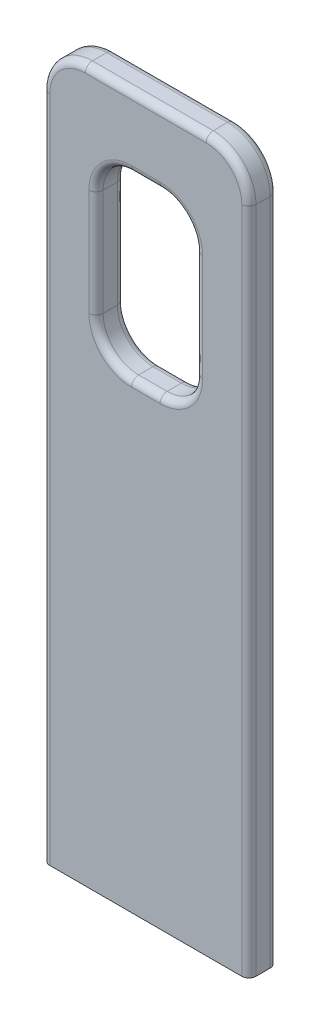
from build123d import *

# Parameters (mm, degrees)
SKETCH1_W      = 2.9
SKETCH1_H      = 10
SKETCH1_W_2    = 1.4
SKETCH1_H_2    = 2.5
EXTRUDE1_DEPTH = 0.2
FILLET1_R      = 0.5
FILLET2_R      = 0.6
FILLET3_R      = 0.1


with BuildPart() as part:
    # Sketch1 → Extrude1 (new body, symmetric)
    with BuildSketch(Plane.XY):
        with Locations((0, 5)):
            Rectangle(SKETCH1_W, SKETCH1_H)
        with Locations((0, 7.75)):
            Rectangle(SKETCH1_W_2, SKETCH1_H_2, mode=Mode.SUBTRACT)
    extrude(amount=EXTRUDE1_DEPTH, both=True)

    # Fillet1
    fillet1_edges = [part.edges().sort_by_distance(p)[0] for p in [
        (-0.7, 9, 0),
        (-0.7, 6.5, 0),
        (0.7, 6.5, 0),
        (0.7, 9, 0),
    ]]
    fillet(fillet1_edges, radius=FILLET1_R)

    # Fillet2
    fillet2_edges = [part.edges().sort_by_distance(p)[0] for p in [
        (-1.45, 10, 0),
        (1.45, 10, 0),
    ]]
    fillet(fillet2_edges, radius=FILLET2_R)

    # Fillet3
    fillet3_edges = [part.edges().sort_by_distance(p)[0] for p in [
        (1.45, 4.7, 0.2),
        (0, 6.5, -0.2),
        (0, 6.5, 0.2),
        (0.7, 7.75, -0.2),
        (0.7, 7.75, 0.2),
        (0, 9, -0.2),
        (0, 9, 0.2),
        (-0.7, 7.75, -0.2),
        (-0.7, 7.75, 0.2),
        (0.553553391, 6.646446609, -0.2),
        (0.553553391, 6.646446609, 0.2),
        (0.553553391, 8.853553391, -0.2),
        (0.553553391, 8.853553391, 0.2),
        (-0.553553391, 8.853553391, -0.2),
        (-0.553553391, 8.853553391, 0.2),
        (-0.553553391, 6.646446609, -0.2),
        (-0.553553391, 6.646446609, 0.2),
        (1.45, 4.7, -0.2),
        (0, 10, -0.2),
        (0, 10, 0.2),
        (-1.45, 4.7, -0.2),
        (-1.274264069, 9.824264069, -0.2),
        (1.274264069, 9.824264069, -0.2),
        (-1.45, 4.7, 0.2),
        (-1.274264069, 9.824264069, 0.2),
        (1.274264069, 9.824264069, 0.2),
    ]]
    fillet(fillet3_edges, radius=FILLET3_R)


solid = part.part
